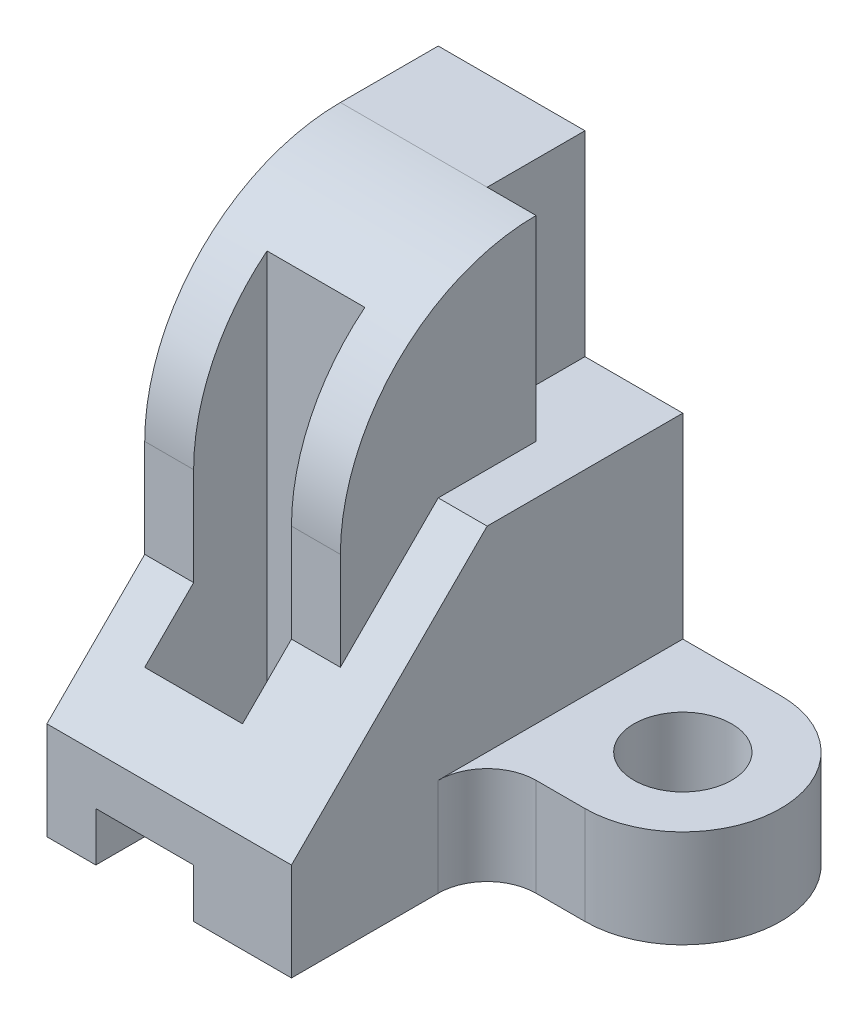
from build123d import *

# Parameters (mm, degrees)
BOSS_EXTRUDE2_DEPTH = 8
SKETCH2_R           = 1
BOSS_EXTRUDE3_DEPTH = 2
CUT_EXTRUDE1_DEPTH  = 4
CUT_EXTRUDE2_DEPTH  = 5
CUT_EXTRUDE3_DEPTH  = 1
SKETCH6_W           = 2
SKETCH6_H           = 2.5
CUT_EXTRUDE4_DEPTH  = 10


with BuildPart() as part:
    # Sketch1 → Boss-Extrude2 (new body)
    with BuildSketch(Plane.XY):
        Polygon((0, 0), (-2, 0), (-2, 1), (-4, 1), (-4, 0), (-5, 0), (-5, 10), (-1, 10), (-1, 6), (0, 6), align=None)
    extrude(amount=BOSS_EXTRUDE2_DEPTH)

    # Sketch2 → Boss-Extrude3 (add)
    with BuildSketch(Plane.XZ):
        with BuildLine():
            Line((0, 0), (2, 0))
            ThreePointArc((2, 0), (4, 2), (2, 4))
            Line((2, 4), (1, 4))
            ThreePointArc((1, 4), (0.292893219, 4.292893219), (0, 5))
            Line((0, 5), (0, 0))
        make_face()
        with Locations((2, 2)):
            Circle(SKETCH2_R, mode=Mode.SUBTRACT)
    extrude(amount=-BOSS_EXTRUDE3_DEPTH)

    # Sketch3 → Cut-Extrude1 (cut)
    with BuildSketch(Plane(origin=(0, 10, 0), x_dir=(1, 0, 0), z_dir=(0, 1, 0))):
        Polygon((-2, 0), (-2, -2), (-1, -2), (-1, -8), (0, -8), (0, 0), align=None)
    extrude(amount=-CUT_EXTRUDE1_DEPTH, mode=Mode.SUBTRACT)

    # Sketch4 → Cut-Extrude2 (cut, symmetric)
    with BuildSketch(Plane(origin=(-1, 0, 0), x_dir=(0, 0, -1), z_dir=(1, 0, 0))):
        with BuildLine():
            Line((-2, 10), (-8, 10))
            Line((-8, 10), (-8, 2))
            Line((-8, 2), (-6, 4))
            Line((-6, 4), (-6, 6))
            ThreePointArc((-6, 6), (-4.828427125, 8.828427125), (-2, 10))
        make_face()
    extrude(amount=CUT_EXTRUDE2_DEPTH, both=True, mode=Mode.SUBTRACT)

    # Sketch5 → Cut-Extrude3 (cut)
    with BuildSketch(Plane(origin=(0, 0, 0), x_dir=(0, 0, -1), z_dir=(1, 0, 0))):
        Polygon((-4, 6), (-6, 4), (-6, 6), align=None)
    extrude(amount=-CUT_EXTRUDE3_DEPTH, mode=Mode.SUBTRACT)

    # Sketch6 → Cut-Extrude4 (cut, through all)
    with BuildSketch(Plane.XZ.offset(-1)):
        with Locations((-3, 5.75)):
            Rectangle(SKETCH6_W, SKETCH6_H)
    extrude(amount=-CUT_EXTRUDE4_DEPTH, mode=Mode.SUBTRACT)


solid = part.part
